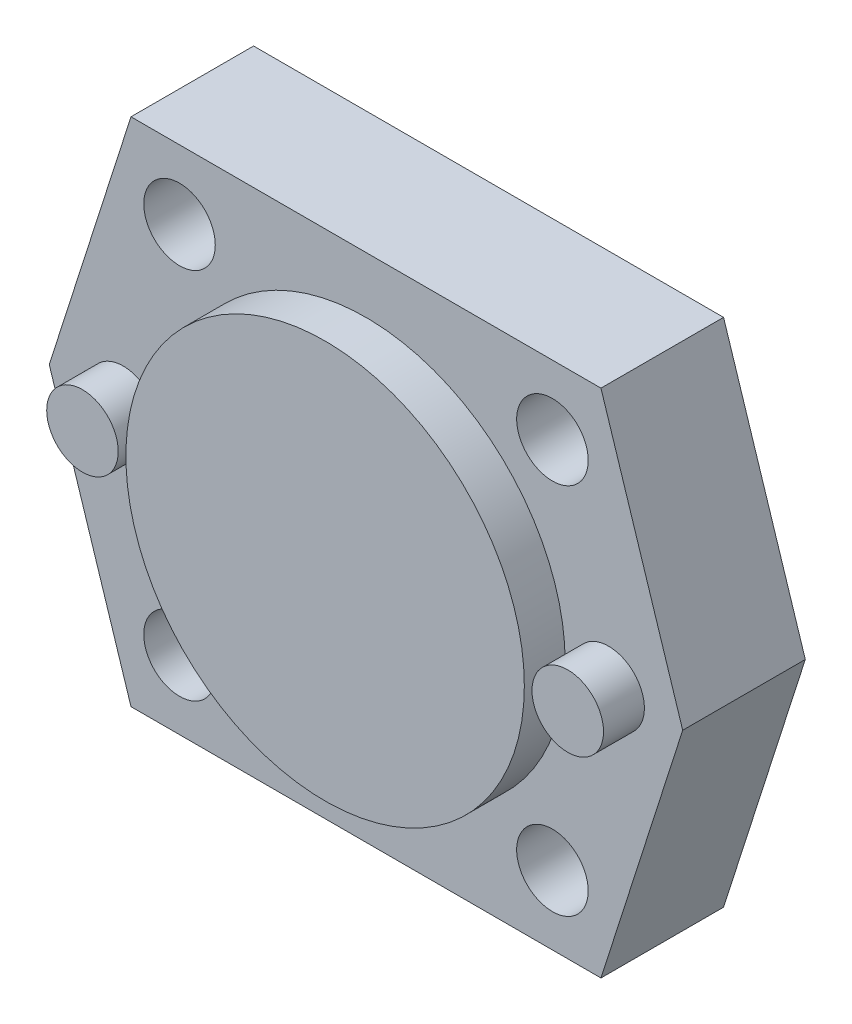
from build123d import *

# Parameters (mm, degrees)
BOSS_EXTRUDE1_DEPTH = 12
SKETCH2_R           = 19.5
SKETCH2_R_2         = 3.5
BOSS_EXTRUDE2_DEPTH = 4
SKETCH3_R           = 3.5
CUT_EXTRUDE1_DEPTH  = 12


with BuildPart() as part:
    # Sketch1 → Boss-Extrude1 (new body)
    with BuildSketch(Plane.XY):
        Polygon((-23, 25), (23, 25), (31, 0), (23, -25), (-23, -25), (-31, 0), align=None)
    extrude(amount=BOSS_EXTRUDE1_DEPTH)

    # Sketch2 → Boss-Extrude2 (add)
    with BuildSketch(Plane.XY.offset(12)):
        Circle(SKETCH2_R)
        with Locations((23.75, 0)):
            Circle(SKETCH2_R_2)
        with Locations((-23.75, 0)):
            Circle(SKETCH2_R_2)
    extrude(amount=BOSS_EXTRUDE2_DEPTH)

    # Sketch3 → Cut-Extrude1 (cut)
    with BuildSketch(Plane.XY.offset(12)):
        with Locations((18.25, 18.25)):
            Circle(SKETCH3_R)
        with Locations((18.25, -18.25)):
            Circle(SKETCH3_R)
        with Locations((-18.25, -18.25)):
            Circle(SKETCH3_R)
        with Locations((-18.25, 18.25)):
            Circle(SKETCH3_R)
    extrude(amount=-CUT_EXTRUDE1_DEPTH, mode=Mode.SUBTRACT)


solid = part.part
